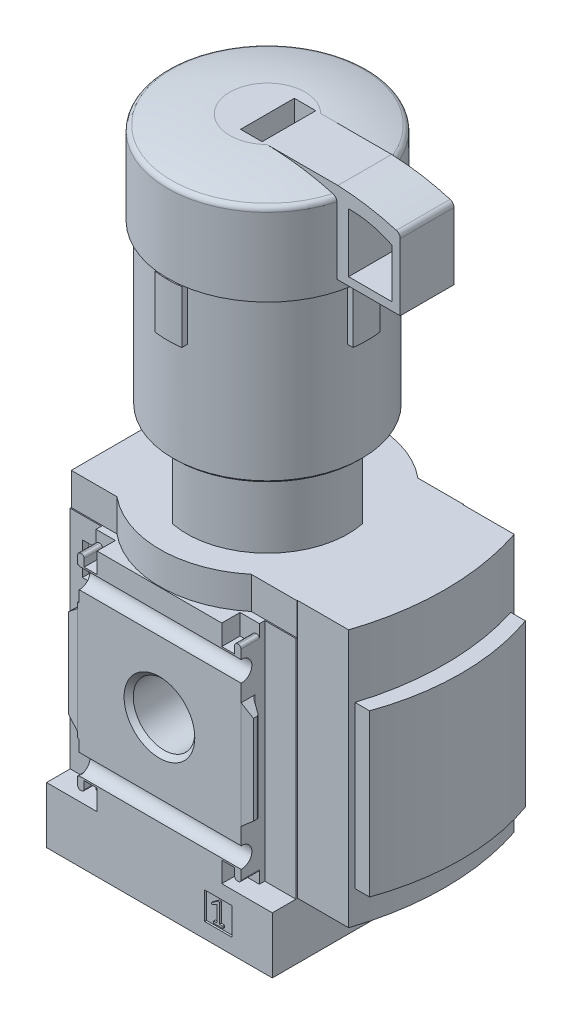
from build123d import *

# Parameters (mm, degrees)
BOSS_EXTRUDE1_DEPTH      = 48
BOSS_EXTRUDE2_DEPTH      = 20.1
BOSS_EXTRUDE2_DEPTH_BACK = 20.1
SKETCH2_W                = 42
SKETCH2_H                = 42
SKETCH3_W                = 42
SKETCH3_H                = 40.2
BOSS_EXTRUDE3_DEPTH      = 10.5
BOSS_EXTRUDE4_DEPTH      = 48
BOSS_EXTRUDE5_DEPTH      = 30
BOSS_EXTRUDE6_DEPTH      = 9.8
SKETCH10_W               = 5.1
SKETCH10_H               = 5.1
CUT_EXTRUDE1_DEPTH       = 0.35
SKETCH11_W               = 5.1
SKETCH11_H               = 5.1
CUT_EXTRUDE2_DEPTH       = 0.35
CUT_EXTRUDE3_DEPTH       = 25
CUT_EXTRUDE3_DEPTH_BACK  = 25
CUT_EXTRUDE4_DEPTH       = 25
CUT_EXTRUDE4_DEPTH_BACK  = 25
BOSS_EXTRUDE7_DEPTH      = 6.5
CUT_EXTRUDE5_DEPTH       = 8.3
CUT_EXTRUDE6_DEPTH       = 3.4
CUT_EXTRUDE6_DEPTH_BACK  = 3.4
CUT_EXTRUDE7_DEPTH       = 3.4
CUT_EXTRUDE7_DEPTH_BACK  = 3.4
CUT_EXTRUDE8_DEPTH       = 3.4
CUT_EXTRUDE8_DEPTH_BACK  = 3.4
CUT_EXTRUDE9_DEPTH       = 3.4
CUT_EXTRUDE9_DEPTH_BACK  = 3.4
CUT_EXTRUDE10_DEPTH      = 21
CUT_EXTRUDE10_DEPTH_BACK = 21
CUT_EXTRUDE11_DEPTH      = 21
CUT_EXTRUDE11_DEPTH_BACK = 21
SKETCH22_W               = 20
SKETCH22_H               = 10
CUT_EXTRUDE12_DEPTH      = 15
BOSS_EXTRUDE8_DEPTH      = 5
BOSS_EXTRUDE8_DEPTH_BACK = 5
CUT_EXTRUDE13_DEPTH      = 13
CUT_EXTRUDE14_DEPTH      = 22
CUT_EXTRUDE14_DEPTH_BACK = 22
SKETCH25_W               = 3.81
SKETCH25_H               = 6.07
CUT_EXTRUDE15_DEPTH      = 22
CUT_EXTRUDE15_DEPTH_BACK = 22
SKETCH26_W               = 3.81
SKETCH26_H               = 6.07
CUT_EXTRUDE16_DEPTH      = 11
CUT_EXTRUDE16_DEPTH_BACK = 11
SKETCH27_W               = 29
SKETCH27_H               = 37.9
BOSS_EXTRUDE9_DEPTH      = 19
BOSS_EXTRUDE9_DEPTH_BACK = 19
BOSS_EXTRUDE10_DEPTH     = 9
BOSS_EXTRUDE11_DEPTH     = 9
SKETCH31_R               = 3.05
BOSS_EXTRUDE12_DEPTH     = 4


with BuildPart() as part:
    # Sketch1 → Boss-Extrude1 (new body)
    with BuildSketch(Plane(origin=(0, 27, 0), x_dir=(1, 0, 0), z_dir=(0, 1, 0))):
        with BuildLine():
            Line((-21, -15.5), (-12.5, -15.5))
            ThreePointArc((-12.5, -15.5), (0, -20), (12.5, -15.5))
            Line((12.5, -15.5), (21, -15.5))
            Line((21, -15.5), (21, 15.5))
            Line((21, 15.5), (12.5, 15.5))
            ThreePointArc((12.5, 15.5), (0, 20), (-12.5, 15.5))
            Line((-12.5, 15.5), (-21, 15.5))
            Line((-21, 15.5), (-21, -15.5))
        make_face()
    extrude(amount=-BOSS_EXTRUDE1_DEPTH)

    # Sketch2 → Boss-Extrude2 (add, two sides: drawn at the far end of the back side and taken through both)
    with BuildSketch(Plane.XY.offset(-BOSS_EXTRUDE2_DEPTH_BACK)):
        Rectangle(SKETCH2_W, SKETCH2_H)
    extrude(amount=BOSS_EXTRUDE2_DEPTH + BOSS_EXTRUDE2_DEPTH_BACK)

    # Sketch3 → Boss-Extrude3 (add)
    with BuildSketch(Plane(origin=(0, -31.5, 0), x_dir=(1, 0, 0), z_dir=(0, 1, 0))):
        Rectangle(SKETCH3_W, SKETCH3_H)
    extrude(amount=BOSS_EXTRUDE3_DEPTH)

    # Sketch4 → Revolve1 (revolve)
    with BuildSketch(Plane(origin=(0, 0, 0), x_dir=(0, 0, -1), z_dir=(1, 0, 0))):
        with BuildLine():
            Line((0, 87.2), (7, 87.2))
            ThreePointArc((7, 87.2), (12.495494003, 86.643164696), (17.881366679, 85.417238343))
            ThreePointArc((17.881366679, 85.417238343), (18.400426973, 85.057068294), (18.6, 84.457638014))
            Line((18.6, 84.457638014), (18.6, 70))
            Line((18.6, 70), (17.6, 70))
            Line((17.6, 70), (17.6, 40.5))
            Line((17.6, 40.5), (17.1, 40))
            Line((17.1, 40), (15, 40))
            Line((15, 40), (15, 27))
            Line((15, 27), (0, 27))
            Line((0, 27), (0, 87.2))
        make_face()
    revolve(axis=Axis((0, 27, 0), (0, 1, 0)))

    # Sketch5 → Boss-Extrude4 (add)
    with BuildSketch(Plane(origin=(0, 27, 0), x_dir=(1, 0, 0), z_dir=(0, 1, 0))):
        with BuildLine():
            Line((20.9, -15.4), (30.5, -15.4))
            ThreePointArc((30.5, -15.4), (33, 0), (30.5, 15.4))
            Line((30.5, 15.4), (20.9, 15.4))
            Line((20.9, 15.4), (20.9, -15.4))
        make_face()
    extrude(amount=-BOSS_EXTRUDE4_DEPTH)

    # Sketch6 → Boss-Extrude5 (add)
    with BuildSketch(Plane(origin=(0, 15, 0), x_dir=(1, 0, 0), z_dir=(0, 1, 0))):
        with BuildLine():
            Line((26, 14.5), (26, -14.5))
            Line((26, -14.5), (33.5, -14.5))
            ThreePointArc((33.5, -14.5), (36, 0), (33.5, 14.5))
            Line((33.5, 14.5), (26, 14.5))
        make_face()
    extrude(amount=-BOSS_EXTRUDE5_DEPTH)

    # Sketch7 → Boss-Extrude6 (add)
    with BuildSketch(Plane(origin=(0, 60, 0), x_dir=(1, 0, 0), z_dir=(0, 1, 0))):
        with BuildLine():
            Line((-18.431223508, -2.5), (-2.5, -2.5))
            Line((-2.5, -2.5), (-2.5, -18.431223508))
            ThreePointArc((-2.5, -18.431223508), (0, -18.6), (2.5, -18.431223508))
            Line((2.5, -18.431223508), (2.5, -2.5))
            Line((2.5, -2.5), (18.431223508, -2.5))
            ThreePointArc((18.431223508, -2.5), (18.6, 0), (18.431223508, 2.5))
            Line((18.431223508, 2.5), (2.5, 2.5))
            Line((2.5, 2.5), (2.5, 18.431223508))
            ThreePointArc((2.5, 18.431223508), (0, 18.6), (-2.5, 18.431223508))
            Line((-2.5, 18.431223508), (-2.5, 2.5))
            Line((-2.5, 2.5), (-18.431223508, 2.5))
            ThreePointArc((-18.431223508, 2.5), (-18.6, 0), (-18.431223508, -2.5))
        make_face()
    extrude(amount=BOSS_EXTRUDE6_DEPTH)

    # Sketch8 → Cut-Revolve1 (revolve, cut)
    with BuildSketch(Plane(origin=(0, 0, 0), x_dir=(0, 0, -1), z_dir=(1, 0, 0))):
        Polygon((-20.1, 0), (-20.1, 6.5785), (-19.244, 5.7225), (-7.799, 5.7225), (-6.943, 6.5785), (-6.943, 0), align=None)
    revolve(axis=Axis((0, 0, 6.943), (0, 0, 1)), mode=Mode.SUBTRACT)

    # Sketch9 → Cut-Revolve2 (revolve, cut)
    with BuildSketch(Plane(origin=(0, 0, 0), x_dir=(0, 0, -1), z_dir=(1, 0, 0))):
        Polygon((6.943, 0), (6.943, 6.5785), (7.799, 5.7225), (19.244, 5.7225), (20.1, 6.5785), (20.1, 0), align=None)
    revolve(axis=Axis((0, 0, -20.1), (0, 0, 1)), mode=Mode.SUBTRACT)

    # Sketch10 → Cut-Extrude1 (cut)
    with BuildSketch(Plane.XY.offset(20.1)):
        with Locations((10.95, -26.14)):
            Rectangle(SKETCH10_W, SKETCH10_H)
        Polygon((9.663200115, -25.02), (9.761292304, -25.275538889), (10.24, -25.062404491), (10.71, -24.78), (10.71, -27.76), (10.1, -27.76), (10.1, -28.14), (11.8, -28.14), (11.8, -27.76), (11.19, -27.76), (11.19, -24.21), (10.82, -24.21), align=None, mode=Mode.SUBTRACT)
    extrude(amount=-CUT_EXTRUDE1_DEPTH, mode=Mode.SUBTRACT)

    # Sketch11 → Cut-Extrude2 (cut)
    with BuildSketch(Plane.XY.offset(-20.1)):
        with Locations((-10.95, -26.14)):
            Rectangle(SKETCH11_W, SKETCH11_H)
        with BuildLine():
            Line((-12.03983262, -25.241503505), (-10.470570303, -27.482642356))
            ThreePointArc((-10.470570303, -27.482642356), (-10.463784424, -27.586174861), (-10.552485507, -27.64))
            Line((-10.552485507, -27.64), (-12.15, -27.64))
            Line((-12.15, -27.64), (-12.15, -28.14))
            Line((-12.15, -28.14), (-9.75, -28.14))
            Line((-9.75, -28.14), (-9.75, -27.64))
            Line((-9.75, -27.64), (-11.575165094, -25.033394109))
            ThreePointArc((-11.575165094, -25.033394109), (-11.592129791, -24.774562847), (-11.370377083, -24.64))
            Line((-11.370377083, -24.64), (-10.75, -24.64))
            ThreePointArc((-10.75, -24.64), (-10.396446609, -24.786446609), (-10.25, -25.14))
            Line((-10.25, -25.14), (-9.75, -25.14))
            ThreePointArc((-9.75, -25.14), (-10.042893219, -24.432893219), (-10.75, -24.14))
            Line((-10.75, -24.14), (-11.466426189, -24.14))
            ThreePointArc((-11.466426189, -24.14), (-12.087333772, -24.516775971), (-12.03983262, -25.241503505))
        make_face(mode=Mode.SUBTRACT)
    extrude(amount=CUT_EXTRUDE2_DEPTH, mode=Mode.SUBTRACT)

    # Sketch12 → Cut-Extrude3 (cut, two sides: drawn at the far end of the back side and taken through both)
    with BuildSketch(Plane(origin=(0, 0, 0), x_dir=(0, 0, -1), z_dir=(1, 0, 0)).offset(-CUT_EXTRUDE3_DEPTH_BACK)):
        with BuildLine():
            Line((21.9, -15), (21.9, 15))
            ThreePointArc((21.9, 15), (18.490033113, 16.153256259), (20.5, 13.166969722))
            Line((20.5, 13.166969722), (20.5, -13.166969722))
            ThreePointArc((20.5, -13.166969722), (18.490033113, -16.153256259), (21.9, -15))
        make_face()
    extrude(amount=CUT_EXTRUDE3_DEPTH + CUT_EXTRUDE3_DEPTH_BACK, mode=Mode.SUBTRACT)

    # Sketch13 → Cut-Extrude4 (cut, two sides: drawn at the far end of the back side and taken through both)
    with BuildSketch(Plane(origin=(0, 0, 0), x_dir=(0, 0, -1), z_dir=(1, 0, 0)).offset(-CUT_EXTRUDE4_DEPTH_BACK)):
        with BuildLine():
            Line((-21.9, 15), (-21.9, -15))
            ThreePointArc((-21.9, -15), (-18.490033113, -16.153256259), (-20.5, -13.166969722))
            Line((-20.5, -13.166969722), (-20.5, 13.166969722))
            ThreePointArc((-20.5, 13.166969722), (-18.490033113, 16.153256259), (-21.9, 15))
        make_face()
    extrude(amount=CUT_EXTRUDE4_DEPTH + CUT_EXTRUDE4_DEPTH_BACK, mode=Mode.SUBTRACT)

    # Sketch14 → Boss-Extrude7 (add)
    with BuildSketch(Plane(origin=(0, -37.4, 0), x_dir=(1, 0, 0), z_dir=(0, 1, 0))):
        Polygon((-9.564954576, -0.433012702), (-5.157477288, -8.066987298), (-4.407477288, -8.5), (4.407477288, -8.5), (5.157477288, -8.066987298), (9.564954576, -0.433012702), (9.564954576, 0.433012702), (5.157477288, 8.066987298), (4.407477288, 8.5), (-4.407477288, 8.5), (-5.157477288, 8.066987298), (-9.564954576, 0.433012702), align=None)
    extrude(amount=BOSS_EXTRUDE7_DEPTH)

    # Sketch15 → Cut-Extrude5 (cut)
    with BuildSketch(Plane(origin=(0, -37.4, 0), x_dir=(1, 0, 0), z_dir=(0, 1, 0))):
        Polygon((-5.196152423, 0), (-2.598076211, -4.5), (2.598076211, -4.5), (5.196152423, 0), (2.598076211, 4.5), (-2.598076211, 4.5), align=None)
    extrude(amount=CUT_EXTRUDE5_DEPTH, mode=Mode.SUBTRACT)

    # Sketch16 → Cut-Extrude6 (cut, two sides: drawn at the far end of the back side and taken through both)
    with BuildSketch(Plane.XY.offset(20.1).offset(-CUT_EXTRUDE6_DEPTH_BACK)):
        with BuildLine():
            Line((11.6, 21), (11.6, 17.2))
            Line((11.6, 17.2), (14, 17.2))
            Line((14, 17.2), (14, 18.6))
            ThreePointArc((14, 18.6), (14.146446609, 18.953553391), (14.5, 19.1))
            Line((14.5, 19.1), (14.7, 19.1))
            ThreePointArc((14.7, 19.1), (15.053553391, 18.953553391), (15.2, 18.6))
            Line((15.2, 18.6), (15.2, 9.95))
            Line((15.2, 9.95), (21.5, 4.663672324))
            Line((21.5, 4.663672324), (21.5, -4.663672324))
            Line((21.5, -4.663672324), (15.2, -9.95))
            Line((15.2, -9.95), (15.2, -18.6))
            ThreePointArc((15.2, -18.6), (15.053553391, -18.953553391), (14.7, -19.1))
            Line((14.7, -19.1), (14.5, -19.1))
            ThreePointArc((14.5, -19.1), (14.146446609, -18.953553391), (14, -18.6))
            Line((14, -18.6), (14, -17.2))
            Line((14, -17.2), (11.6, -17.2))
            Line((11.6, -17.2), (11.6, -21))
            Line((11.6, -21), (22, -21))
            Line((22, -21), (22, 21))
            Line((22, 21), (11.6, 21))
        make_face()
    extrude(amount=CUT_EXTRUDE6_DEPTH + CUT_EXTRUDE6_DEPTH_BACK, mode=Mode.SUBTRACT)

    # Sketch17 → Cut-Extrude7 (cut, two sides: drawn at the far end of the back side and taken through both)
    with BuildSketch(Plane.XY.offset(20.1).offset(-CUT_EXTRUDE7_DEPTH_BACK)):
        with BuildLine():
            Line((-22, -21), (-11.6, -21))
            Line((-11.6, -21), (-11.6, -17.2))
            Line((-11.6, -17.2), (-14, -17.2))
            Line((-14, -17.2), (-14, -18.6))
            ThreePointArc((-14, -18.6), (-14.146446609, -18.953553391), (-14.5, -19.1))
            Line((-14.5, -19.1), (-14.7, -19.1))
            ThreePointArc((-14.7, -19.1), (-15.053553391, -18.953553391), (-15.2, -18.6))
            Line((-15.2, -18.6), (-15.2, -9.95))
            Line((-15.2, -9.95), (-21.5, -4.663672324))
            Line((-21.5, -4.663672324), (-21.5, 4.663672324))
            Line((-21.5, 4.663672324), (-15.2, 9.95))
            Line((-15.2, 9.95), (-15.2, 18.6))
            ThreePointArc((-15.2, 18.6), (-15.053553391, 18.953553391), (-14.7, 19.1))
            Line((-14.7, 19.1), (-14.5, 19.1))
            ThreePointArc((-14.5, 19.1), (-14.146446609, 18.953553391), (-14, 18.6))
            Line((-14, 18.6), (-14, 17.2))
            Line((-14, 17.2), (-11.6, 17.2))
            Line((-11.6, 17.2), (-11.6, 21))
            Line((-11.6, 21), (-22, 21))
            Line((-22, 21), (-22, -21))
        make_face()
    extrude(amount=CUT_EXTRUDE7_DEPTH + CUT_EXTRUDE7_DEPTH_BACK, mode=Mode.SUBTRACT)

    # Sketch18 → Cut-Extrude8 (cut, two sides: drawn at the far end of the back side and taken through both)
    with BuildSketch(Plane.XY.offset(-20.1).offset(-CUT_EXTRUDE8_DEPTH_BACK)):
        with BuildLine():
            Line((11.6, 21), (11.6, 17.2))
            Line((11.6, 17.2), (14, 17.2))
            Line((14, 17.2), (14, 18.6))
            ThreePointArc((14, 18.6), (14.146446609, 18.953553391), (14.5, 19.1))
            Line((14.5, 19.1), (14.7, 19.1))
            ThreePointArc((14.7, 19.1), (15.053553391, 18.953553391), (15.2, 18.6))
            Line((15.2, 18.6), (15.2, 9.95))
            Line((15.2, 9.95), (21.5, 4.663672324))
            Line((21.5, 4.663672324), (21.5, -4.663672324))
            Line((21.5, -4.663672324), (15.2, -9.95))
            Line((15.2, -9.95), (15.2, -18.6))
            ThreePointArc((15.2, -18.6), (15.053553391, -18.953553391), (14.7, -19.1))
            Line((14.7, -19.1), (14.5, -19.1))
            ThreePointArc((14.5, -19.1), (14.146446609, -18.953553391), (14, -18.6))
            Line((14, -18.6), (14, -17.2))
            Line((14, -17.2), (11.6, -17.2))
            Line((11.6, -17.2), (11.6, -21))
            Line((11.6, -21), (22, -21))
            Line((22, -21), (22, 21))
            Line((22, 21), (11.6, 21))
        make_face()
    extrude(amount=CUT_EXTRUDE8_DEPTH + CUT_EXTRUDE8_DEPTH_BACK, mode=Mode.SUBTRACT)

    # Sketch19 → Cut-Extrude9 (cut, two sides: drawn at the far end of the back side and taken through both)
    with BuildSketch(Plane.XY.offset(-20.1).offset(-CUT_EXTRUDE9_DEPTH_BACK)):
        with BuildLine():
            Line((-22, -21), (-11.6, -21))
            Line((-11.6, -21), (-11.6, -17.2))
            Line((-11.6, -17.2), (-14, -17.2))
            Line((-14, -17.2), (-14, -18.6))
            ThreePointArc((-14, -18.6), (-14.146446609, -18.953553391), (-14.5, -19.1))
            Line((-14.5, -19.1), (-14.7, -19.1))
            ThreePointArc((-14.7, -19.1), (-15.053553391, -18.953553391), (-15.2, -18.6))
            Line((-15.2, -18.6), (-15.2, -9.95))
            Line((-15.2, -9.95), (-21.5, -4.663672324))
            Line((-21.5, -4.663672324), (-21.5, 4.663672324))
            Line((-21.5, 4.663672324), (-15.2, 9.95))
            Line((-15.2, 9.95), (-15.2, 18.6))
            ThreePointArc((-15.2, 18.6), (-15.053553391, 18.953553391), (-14.7, 19.1))
            Line((-14.7, 19.1), (-14.5, 19.1))
            ThreePointArc((-14.5, 19.1), (-14.146446609, 18.953553391), (-14, 18.6))
            Line((-14, 18.6), (-14, 17.2))
            Line((-14, 17.2), (-11.6, 17.2))
            Line((-11.6, 17.2), (-11.6, 21))
            Line((-11.6, 21), (-22, 21))
            Line((-22, 21), (-22, -21))
        make_face()
    extrude(amount=CUT_EXTRUDE9_DEPTH + CUT_EXTRUDE9_DEPTH_BACK, mode=Mode.SUBTRACT)

    # Sketch20 → Cut-Extrude10 (cut, two sides: drawn at the far end of the back side and taken through both)
    with BuildSketch(Plane(origin=(0, 0, 0), x_dir=(1, 0, 0), z_dir=(0, 1, 0)).offset(-CUT_EXTRUDE10_DEPTH_BACK)):
        with BuildLine():
            Line((-22.2, 25.1), (-22.2, 15.7))
            Line((-22.2, 15.7), (-15.2, 15.7))
            Line((-15.2, 15.7), (-15.2, 17.400104518))
            ThreePointArc((-15.2, 17.400104518), (-15.321561523, 17.82403993), (-15.649303083, 18.119139756))
            Line((-15.649303083, 18.119139756), (-16.919185573, 18.73850283))
            ThreePointArc((-16.919185573, 18.73850283), (-17.124024048, 18.922940221), (-17.2, 19.187899853))
            Line((-17.2, 19.187899853), (-17.2, 19.8))
            Line((-17.2, 19.8), (-15.2, 20.1))
            Line((-15.2, 20.1), (15.2, 20.1))
            Line((15.2, 20.1), (17.2, 19.8))
            Line((17.2, 19.8), (17.2, 19.187899853))
            ThreePointArc((17.2, 19.187899853), (17.124024048, 18.922940221), (16.919185573, 18.73850283))
            Line((16.919185573, 18.73850283), (15.649303083, 18.119139756))
            ThreePointArc((15.649303083, 18.119139756), (15.321561523, 17.82403993), (15.2, 17.400104518))
            Line((15.2, 17.400104518), (15.2, 15.7))
            Line((15.2, 15.7), (22.2, 15.7))
            Line((22.2, 15.7), (22.2, 25.1))
            Line((22.2, 25.1), (-22.2, 25.1))
        make_face()
    extrude(amount=CUT_EXTRUDE10_DEPTH + CUT_EXTRUDE10_DEPTH_BACK, mode=Mode.SUBTRACT)

    # Sketch21 → Cut-Extrude11 (cut, two sides: drawn at the far end of the back side and taken through both)
    with BuildSketch(Plane(origin=(0, 0, 0), x_dir=(1, 0, 0), z_dir=(0, 1, 0)).offset(-CUT_EXTRUDE11_DEPTH_BACK)):
        with BuildLine():
            Line((-22.2, -15.7), (-22.2, -25.1))
            Line((-22.2, -25.1), (22.2, -25.1))
            Line((22.2, -25.1), (22.2, -15.7))
            Line((22.2, -15.7), (15.2, -15.7))
            Line((15.2, -15.7), (15.2, -17.400104518))
            ThreePointArc((15.2, -17.400104518), (15.321561523, -17.82403993), (15.649303083, -18.119139756))
            Line((15.649303083, -18.119139756), (16.919185573, -18.73850283))
            ThreePointArc((16.919185573, -18.73850283), (17.124024048, -18.922940221), (17.2, -19.187899853))
            Line((17.2, -19.187899853), (17.2, -19.8))
            Line((17.2, -19.8), (15.2, -20.1))
            Line((15.2, -20.1), (-15.2, -20.1))
            Line((-15.2, -20.1), (-17.2, -19.8))
            Line((-17.2, -19.8), (-17.2, -19.187899853))
            ThreePointArc((-17.2, -19.187899853), (-17.124024048, -18.922940221), (-16.919185573, -18.73850283))
            Line((-16.919185573, -18.73850283), (-15.649303083, -18.119139756))
            ThreePointArc((-15.649303083, -18.119139756), (-15.321561523, -17.82403993), (-15.2, -17.400104518))
            Line((-15.2, -17.400104518), (-15.2, -15.7))
            Line((-15.2, -15.7), (-22.2, -15.7))
        make_face()
    extrude(amount=CUT_EXTRUDE11_DEPTH + CUT_EXTRUDE11_DEPTH_BACK, mode=Mode.SUBTRACT)

    # Sketch22 → Cut-Extrude12 (cut)
    with BuildSketch(Plane(origin=(0, 87.2, 0), x_dir=(1, 0, 0), z_dir=(0, 1, 0))):
        with Locations((10, 0)):
            Rectangle(SKETCH22_W, SKETCH22_H)
    extrude(amount=-CUT_EXTRUDE12_DEPTH, mode=Mode.SUBTRACT)

    # Sketch23 → Boss-Extrude8 (add, two sides: drawn at the far end of the back side and taken through both)
    with BuildSketch(Plane.XY.offset(-BOSS_EXTRUDE8_DEPTH_BACK)):
        with BuildLine():
            Line((4, 72), (29.7, 72))
            Line((29.7, 72), (29.7, 84.457638014))
            ThreePointArc((29.7, 84.457638014), (29.500426973, 85.057068294), (28.981366679, 85.417238343))
            ThreePointArc((28.981366679, 85.417238343), (23.595494003, 86.643164696), (18.1, 87.2))
            Line((18.1, 87.2), (4, 87.2))
            Line((4, 87.2), (4, 72))
        make_face()
        with BuildLine():
            Line((20.1, 84.457638014), (20.1, 73.5))
            Line((20.1, 73.5), (28.2, 73.5))
            Line((28.2, 73.5), (28.2, 82.6))
            ThreePointArc((28.2, 82.6), (24.258672399, 84.002671516), (20.1, 84.457638014))
        make_face(mode=Mode.SUBTRACT)
    extrude(amount=BOSS_EXTRUDE8_DEPTH + BOSS_EXTRUDE8_DEPTH_BACK)

    # Sketch24 → Cut-Extrude13 (cut)
    with BuildSketch(Plane(origin=(0, 27, 0), x_dir=(1, 0, 0), z_dir=(0, 1, 0))):
        Polygon((-49.497474683, 7.071067812), (7.071067812, -49.497474683), (49.497474683, -7.071067812), (-7.071067812, 49.497474683), align=None)
        Polygon((-30.0520382, 12.374368671), (12.374368671, -30.0520382), (30.0520382, -12.374368671), (-12.374368671, 30.0520382), align=None, mode=Mode.SUBTRACT)
    extrude(amount=CUT_EXTRUDE13_DEPTH, mode=Mode.SUBTRACT)

    # Sketch25 → Cut-Extrude14 (cut, two sides: drawn at the far end of the back side and taken through both)
    with BuildSketch(Plane.XY.offset(-CUT_EXTRUDE14_DEPTH_BACK)):
        with Locations((-16.825, 14.005)):
            Rectangle(SKETCH25_W, SKETCH25_H)
    extrude(amount=CUT_EXTRUDE14_DEPTH + CUT_EXTRUDE14_DEPTH_BACK, mode=Mode.SUBTRACT)

    # Sketch26 → Cut-Extrude15 (cut, two sides: drawn at the far end of the back side and taken through both)
    with BuildSketch(Plane.XY.offset(-CUT_EXTRUDE15_DEPTH_BACK)):
        with Locations((-16.825, -13.995)):
            Rectangle(SKETCH26_W, SKETCH26_H)
    extrude(amount=CUT_EXTRUDE15_DEPTH + CUT_EXTRUDE15_DEPTH_BACK, mode=Mode.SUBTRACT)

    # Sketch27 → Cut-Extrude16 (cut, two sides: drawn at the far end of the back side and taken through both)
    with BuildSketch(Plane(origin=(-21, 0, 0), x_dir=(0, 0, -1), z_dir=(1, 0, 0)).offset(-CUT_EXTRUDE16_DEPTH_BACK)):
        Rectangle(SKETCH27_W, SKETCH27_H)
    extrude(amount=CUT_EXTRUDE16_DEPTH + CUT_EXTRUDE16_DEPTH_BACK, mode=Mode.SUBTRACT)

    # Sketch28 → Boss-Extrude9 (add, two sides: drawn at the far end of the back side and taken through both)
    with BuildSketch(Plane(origin=(0, 0, 0), x_dir=(1, 0, 0), z_dir=(0, 1, 0)).offset(-BOSS_EXTRUDE9_DEPTH_BACK)):
        with BuildLine():
            Line((-11.489125293, -14.5), (-10, -14.5))
            Line((-10, -14.5), (-10, 14.5))
            Line((-10, 14.5), (-11.489125293, 14.5))
            ThreePointArc((-11.489125293, 14.5), (-18.5, 0), (-11.489125293, -14.5))
        make_face()
    extrude(amount=BOSS_EXTRUDE9_DEPTH + BOSS_EXTRUDE9_DEPTH_BACK)

    # Sketch29 → Boss-Extrude10 (add)
    with BuildSketch(Plane(origin=(-19.9, 0, 0), x_dir=(0, 0, -1), z_dir=(1, 0, 0))):
        with BuildLine():
            Line((8.8, -21.3), (14.6, -21.3))
            Line((14.6, -21.3), (14.6, -17.1))
            Line((14.6, -17.1), (13.163330765, -17.1))
            ThreePointArc((13.163330765, -17.1), (10.799161363, -15.309186489), (8.8, -17.5))
            Line((8.8, -17.5), (8.8, -21.3))
        make_face()
    extrude(amount=BOSS_EXTRUDE10_DEPTH)

    # Sketch30 → Boss-Extrude11 (add)
    with BuildSketch(Plane(origin=(-19.9, 0, 0), x_dir=(0, 0, -1), z_dir=(1, 0, 0))):
        with BuildLine():
            Line((-14.6, 17.1), (-13.163330765, 17.1))
            ThreePointArc((-13.163330765, 17.1), (-10.799161363, 15.309186489), (-8.8, 17.5))
            Line((-8.8, 17.5), (-8.8, 21.3))
            Line((-8.8, 21.3), (-14.6, 21.3))
            Line((-14.6, 21.3), (-14.6, 17.1))
        make_face()
    extrude(amount=BOSS_EXTRUDE11_DEPTH)

    # Sketch31 → Boss-Extrude12 (add)
    with BuildSketch(Plane(origin=(-18, 0, 0), x_dir=(0, 0, -1), z_dir=(1, 0, 0))):
        with Locations((8.6, 6)):
            Circle(SKETCH31_R)
    extrude(amount=BOSS_EXTRUDE12_DEPTH)


solid = part.part
